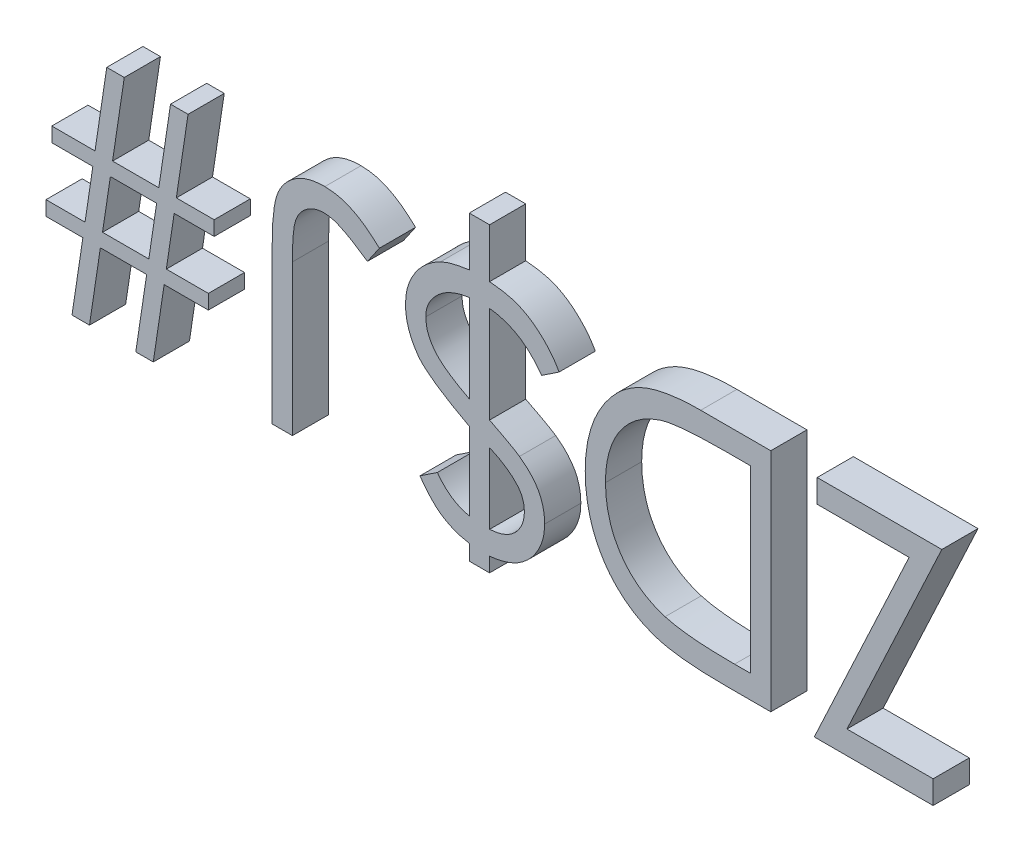
from build123d import *

# Parameters (mm, degrees)
BOSS_EXTRUDE1_DEPTH   = 2.54
BOSS_EXTRUDE1_2_DEPTH = 2.54
BOSS_EXTRUDE1_3_DEPTH = 2.54
BOSS_EXTRUDE1_4_DEPTH = 2.54
BOSS_EXTRUDE1_5_DEPTH = 2.54


with BuildPart() as part:
    # Sketch1 → Boss-Extrude1 (new body)
    with BuildSketch(Plane.XY):
        Polygon((34.338846154, -14.246794872), (34.338846154, -15.875), (25.994294872, -15.875), (32.653399439, -1.628205128), (26.197820513, -1.628205128), (26.197820513, 0), (34.949423077, 0), (28.29031851, -14.246794872), align=None)
    extrude(amount=BOSS_EXTRUDE1_DEPTH)


with BuildPart() as body_2:
    # Sketch1 → Boss-Extrude1 2 (new body)
    with BuildSketch(Plane.XY):
        with BuildLine():
            Line((22.941410256, 0), (22.941410256, -15.875))
            Line((22.941410256, -15.875), (19.73588141, -15.875))
            add(Edge.make_bspline(
                [(19.73588141, -15.875), (19.457075063, -15.872998099), (18.91842265, -15.869130436), (18.140045384, -15.844467286), (17.420874812, -15.801278666), (16.76131934, -15.737155857), (16.160319341, -15.660190517), (15.618837383, -15.56230982), (15.135995956, -15.447195493), (14.83904586, -15.349013294), (14.698621795, -15.302584135)],
                knots=[0, 0, 0, 0, 1.314317071, 2.539253741, 3.67075822, 4.709970291, 5.662644612, 6.526156501, 7.303037452, 8, 8, 8, 8], degree=3))
            add(Edge.make_bspline(
                [(14.698621795, -15.302584135), (14.514932802, -15.23261658), (14.151720273, -15.094268102), (13.634854986, -14.832893895), (13.146633863, -14.537956411), (12.69091192, -14.202693754), (12.266684995, -13.831390189), (11.868615395, -13.427049857), (11.508113044, -12.978878232), (11.172744111, -12.500781919), (10.87920928, -11.988410139), (10.620367969, -11.452025632), (10.399356786, -10.89266914), (10.226908698, -10.306259298), (10.084436776, -9.69842834), (9.988841612, -9.064574245), (9.925341587, -8.408392429), (9.918991318, -7.963095381), (9.915769231, -7.737154447)],
                knots=[0, 0, 0, 0, 0.984696416, 1.947063185, 2.89840987, 3.841051395, 4.778753227, 5.721858861, 6.681155121, 7.65838316, 8.646299769, 9.637283673, 10.641736726, 11.657050558, 12.698485921, 13.768600492, 14.86780186, 16, 16, 16, 16], degree=3))
            add(Edge.make_bspline(
                [(9.915769231, -7.737154447), (9.918623972, -7.540934495), (9.924249538, -7.154262585), (9.974701386, -6.584381856), (10.048173222, -6.031451531), (10.161401466, -5.497899467), (10.300533706, -4.980133415), (10.472258365, -4.480604918), (10.675795689, -3.998974465), (10.911841175, -3.539067515), (11.170301352, -3.10200239), (11.451936145, -2.694704109), (11.747102558, -2.312682032), (12.066565843, -1.964566462), (12.399748897, -1.639516975), (12.757983739, -1.351952797), (13.130053612, -1.08852382), (13.527136575, -0.857229931), (13.952490545, -0.651487142), (14.417226371, -0.477736124), (14.919647899, -0.328210428), (15.463084275, -0.209078587), (16.045723088, -0.113052279), (16.669143739, -0.049103688), (17.332178831, -0.005738563), (17.787471995, -0.001949996), (18.021813902, 0)],
                knots=[0, 0, 0, 0, 1.105894396, 2.179280415, 3.222964075, 4.248423888, 5.251546139, 6.243661943, 7.223682738, 8.196462441, 9.155694589, 10.083899862, 10.986397372, 11.874737962, 12.745335529, 13.607670254, 14.461432187, 15.313100333, 16.195087267, 17.121790994, 18.106827133, 19.14775296, 20.255889161, 21.433815148, 22.679170477, 24, 24, 24, 24], degree=3))
            Line((18.021813902, 0), (22.941410256, 0))
        make_face()
        with BuildLine():
            Line((21.516730769, -1.628205128), (19.694540264, -1.628205128))
            add(Edge.make_bspline(
                [(19.694540264, -1.628205128), (19.432700869, -1.629330422), (18.929087819, -1.631494775), (18.204924759, -1.650486733), (17.543257497, -1.681519806), (16.943992079, -1.724949623), (16.407466862, -1.782410842), (15.932560568, -1.846477365), (15.520829932, -1.926294374), (15.2716857, -1.998643369), (15.156554487, -2.032076322)],
                knots=[0, 0, 0, 0, 1.375205317, 2.645023457, 3.804390687, 4.853969522, 5.800190428, 6.637939096, 7.370582563, 8, 8, 8, 8], degree=3))
            add(Edge.make_bspline(
                [(15.156554487, -2.032076322), (15.011642766, -2.083106363), (14.725280536, -2.183947592), (14.313114425, -2.36796069), (13.928516594, -2.585662374), (13.565075396, -2.829083268), (13.225126547, -3.101982027), (12.910244326, -3.405226531), (12.61794155, -3.735306055), (12.352898266, -4.093332811), (12.113187642, -4.475334316), (11.906078452, -4.880885049), (11.73148775, -5.307709206), (11.588247686, -5.754321793), (11.476569553, -6.220988618), (11.397943753, -6.708880783), (11.349220267, -7.21780561), (11.343404447, -7.564259137), (11.340448718, -7.740334535)],
                knots=[0, 0, 0, 0, 0.998420628, 1.972994, 2.929372424, 3.86770908, 4.81360496, 5.759023883, 6.706048443, 7.676227424, 8.651287839, 9.634325482, 10.632389399, 11.645655052, 12.680158286, 13.74837235, 14.855672678, 16, 16, 16, 16], degree=3))
            add(Edge.make_bspline(
                [(11.340448718, -7.740334535), (11.342779324, -7.925995995), (11.347357821, -8.290729576), (11.404809694, -8.825917417), (11.488945637, -9.340576124), (11.609968629, -9.835076229), (11.766319899, -10.308774375), (11.953406866, -10.764346754), (12.180559812, -11.195930585), (12.437720961, -11.607181217), (12.726431449, -11.99187052), (13.045410565, -12.345491653), (13.391294871, -12.668703328), (13.762490293, -12.962020149), (14.164186769, -13.220225882), (14.589586804, -13.449921673), (15.044682726, -13.645084876), (15.361339128, -13.748849246), (15.522264623, -13.801582532)],
                knots=[0, 0, 0, 0, 1.122272916, 2.204715076, 3.251197285, 4.274229216, 5.279697671, 6.265416158, 7.248880903, 8.225321784, 9.195852973, 10.153576302, 11.101466393, 12.055578741, 13.010401466, 13.985536859, 14.976245305, 16, 16, 16, 16], degree=3))
            add(Edge.make_bspline(
                [(15.522264623, -13.801582532), (15.655393037, -13.83839633), (15.938460572, -13.916672565), (16.400375284, -14.002059076), (16.920236854, -14.077372339), (17.500353356, -14.141135589), (18.140063509, -14.186888797), (18.839859309, -14.221230116), (19.600043229, -14.244392342), (20.127014008, -14.245973979), (20.400519832, -14.246794872)],
                knots=[0, 0, 0, 0, 0.674548936, 1.434276114, 2.292660221, 3.240891867, 4.284742987, 5.42552168, 6.663806718, 8, 8, 8, 8], degree=3))
            Line((20.400519832, -14.246794872), (21.516730769, -14.246794872))
            Line((21.516730769, -14.246794872), (21.516730769, -1.628205128))
        make_face(mode=Mode.SUBTRACT)
    extrude(amount=BOSS_EXTRUDE1_2_DEPTH)


with BuildPart() as body_3:
    # Sketch1 → Boss-Extrude1 3 (new body)
    with BuildSketch(Plane.XY):
        with BuildLine():
            Line((3.199423077, -17.299679487), (1.77474359, -17.299679487))
            Line((1.77474359, -17.299679487), (1.77474359, -16.215269431))
            add(Edge.make_bspline(
                [(1.77474359, -16.215269431), (1.592542457, -16.179897121), (1.238430723, -16.111150293), (0.733066392, -15.945845099), (0.269109359, -15.737068817), (-0.161718203, -15.48116222), (-0.563596033, -15.163924674), (-0.948438666, -14.78317721), (-1.331631903, -14.341404327), (-1.564081734, -14.011585287), (-1.685192308, -13.83974359)],
                knots=[0, 0, 0, 0, 1.027356147, 1.996688285, 2.937535733, 3.840857787, 4.765308625, 5.766057359, 6.836075402, 8, 8, 8, 8], degree=3))
            Line((-1.685192308, -13.83974359), (-0.464038462, -13.025641026))
            add(Edge.make_bspline(
                [(-0.464038462, -13.025641026), (-0.389365788, -13.125546929), (-0.242345453, -13.322248057), (0.003132858, -13.590045804), (0.265400055, -13.825655759), (0.538740275, -14.033859757), (0.826307873, -14.210045089), (1.128329699, -14.353454283), (1.443836134, -14.470855579), (1.663799993, -14.520622247), (1.77474359, -14.545723157)],
                knots=[0, 0, 0, 0, 1.07895845, 2.124322375, 3.137595321, 4.126531539, 5.094133059, 6.050184892, 7.016567989, 8, 8, 8, 8], degree=3))
            Line((1.77474359, -14.545723157), (1.77474359, -9.095052083))
            add(Edge.make_bspline(
                [(1.77474359, -9.095052083), (1.546118831, -8.972318984), (1.108263844, -8.737264391), (0.49222975, -8.380133331), (-0.059576881, -8.045719891), (-0.540213752, -7.723841094), (-0.955302061, -7.422967826), (-1.302643821, -7.141112724), (-1.586250775, -6.879237383), (-1.734672311, -6.69571257), (-1.802855569, -6.611403245)],
                knots=[0, 0, 0, 0, 1.421563521, 2.722533998, 3.90086193, 4.955909988, 5.891017391, 6.708270612, 7.406593414, 8, 8, 8, 8], degree=3))
            add(Edge.make_bspline(
                [(-1.802855569, -6.611403245), (-1.874291682, -6.509558197), (-2.016115683, -6.307362532), (-2.200710502, -5.990152427), (-2.352792444, -5.663319335), (-2.482011875, -5.331595266), (-2.581029824, -4.989949331), (-2.64905919, -4.639649138), (-2.697371466, -4.282795236), (-2.70099778, -4.042054671), (-2.702820513, -3.921048678)],
                knots=[0, 0, 0, 0, 1.034145216, 2.053115814, 3.046762578, 4.028927166, 5.01085441, 5.99964147, 6.994538498, 8, 8, 8, 8], degree=3))
            add(Edge.make_bspline(
                [(-2.702820513, -3.921048678), (-2.695006426, -3.721137582), (-2.679555409, -3.32584764), (-2.552098431, -2.74706121), (-2.338358002, -2.197927792), (-2.048206616, -1.678898432), (-1.687089521, -1.2009681), (-1.2633539, -0.774651282), (-0.782462739, -0.403123714), (-0.425596744, -0.207389487), (-0.24461238, -0.108122997)],
                knots=[0, 0, 0, 0, 1.003260286, 1.983775336, 2.959596404, 3.953447525, 4.960711395, 5.95830558, 6.964555965, 8, 8, 8, 8], degree=3))
            add(Edge.make_bspline(
                [(-0.24461238, -0.108122997), (-0.112048803, -0.050356425), (0.170954882, 0.072966685), (0.644794651, 0.212171138), (1.186574311, 0.324655833), (1.571890331, 0.378633978), (1.77474359, 0.407051282)],
                knots=[0, 0, 0, 0, 0.828676495, 1.769102089, 2.82552272, 4, 4, 4, 4], degree=3))
            Line((1.77474359, 0.407051282), (1.77474359, 3.866987179))
            Line((1.77474359, 3.866987179), (3.199423077, 3.866987179))
            Line((3.199423077, 3.866987179), (3.199423077, 0.407051282))
            add(Edge.make_bspline(
                [(3.199423077, 0.407051282), (3.407498184, 0.387426022), (3.802992044, 0.350123773), (4.361660452, 0.256288418), (4.85450537, 0.130152946), (5.292793113, -0.027971117), (5.693824473, -0.226838292), (6.084657419, -0.458147007), (6.464916471, -0.742029963), (6.841076142, -1.059341256), (7.198065533, -1.412867809), (7.52679408, -1.797335084), (7.82823714, -2.205641591), (7.998670808, -2.498929729), (8.084038462, -2.645833333)],
                knots=[0, 0, 0, 0, 1.246672502, 2.369583394, 3.375855167, 4.278204361, 5.143720243, 6.042872285, 6.983993976, 7.97112367, 8.977335818, 9.977487593, 10.986954044, 12, 12, 12, 12], degree=3))
            Line((8.084038462, -2.645833333), (6.862884615, -3.459935897))
            add(Edge.make_bspline(
                [(6.862884615, -3.459935897), (6.740708101, -3.299568614), (6.501672371, -2.985813463), (6.101002875, -2.565267108), (5.680911857, -2.195397769), (5.232812351, -1.884840846), (4.759256474, -1.631058773), (4.259923549, -1.43806258), (3.738891067, -1.294397731), (3.380401061, -1.245725333), (3.199423077, -1.221153846)],
                knots=[0, 0, 0, 0, 1.091171576, 2.134853779, 3.139926003, 4.117738301, 5.080879018, 6.042512846, 7.011793711, 8, 8, 8, 8], degree=3))
            Line((3.199423077, -1.221153846), (3.199423077, -8.007461939))
            add(Edge.make_bspline(
                [(3.199423077, -8.007461939), (3.332183799, -8.074810385), (3.584619721, -8.202869095), (3.940907673, -8.393267761), (4.262091223, -8.558903845), (4.543006968, -8.713545424), (4.78765388, -8.848850835), (4.993057722, -8.96913257), (5.161057994, -9.071281987), (5.25817693, -9.136117733), (5.301461338, -9.165014022)],
                knots=[0, 0, 0, 0, 1.488099822, 2.829525506, 4.038191342, 5.100394068, 6.034941972, 6.832791195, 7.479793087, 8, 8, 8, 8], degree=3))
            add(Edge.make_bspline(
                [(5.301461338, -9.165014022), (5.443650755, -9.272516804), (5.719294889, -9.48091847), (6.084404062, -9.830252403), (6.392556626, -10.195943645), (6.641753252, -10.583780433), (6.836289548, -10.994599215), (6.967814182, -11.436587467), (7.054714475, -11.907069086), (7.062445055, -12.232329676), (7.066410256, -12.399163662)],
                knots=[0, 0, 0, 0, 1.111703063, 2.15511418, 3.146123089, 4.089346267, 5.024531557, 5.972475508, 6.960033881, 8, 8, 8, 8], degree=3))
            add(Edge.make_bspline(
                [(7.066410256, -12.399163662), (7.061244271, -12.561760946), (7.051001255, -12.884155696), (6.958731677, -13.357969857), (6.8082315, -13.814400968), (6.598102928, -14.246799044), (6.340620976, -14.651842818), (6.037408749, -15.020730427), (5.686535788, -15.345516483), (5.296887915, -15.637205033), (4.851821891, -15.876187299), (4.353339026, -16.067887209), (3.796857954, -16.207883891), (3.403674889, -16.256694838), (3.199423077, -16.282051282)],
                knots=[0, 0, 0, 0, 0.966461706, 1.916281572, 2.859484747, 3.818408359, 4.768270089, 5.708876967, 6.650223357, 7.606219079, 8.596637969, 9.644717611, 10.77647148, 12, 12, 12, 12], degree=3))
            Line((3.199423077, -16.282051282), (3.199423077, -17.299679487))
        make_face()
        with BuildLine():
            add(Edge.make_bspline(
                [(3.199423077, -14.653846154), (3.332245739, -14.640369261), (3.585912227, -14.614630912), (3.945002857, -14.539623448), (4.261288077, -14.430889943), (4.542387592, -14.297314644), (4.784076493, -14.127568962), (5.004688313, -13.940607698), (5.191695634, -13.722202546), (5.351802898, -13.481965211), (5.482371063, -13.223195469), (5.575627741, -12.946027217), (5.630061892, -12.655708577), (5.637818758, -12.457689347), (5.641730769, -12.357822516)],
                knots=[0, 0, 0, 0, 1.288708572, 2.461192779, 3.532677332, 4.512365405, 5.454988357, 6.376533455, 7.298078554, 8.22075996, 9.159205215, 10.08822426, 11.035836136, 12, 12, 12, 12], degree=3))
            add(Edge.make_bspline(
                [(5.641730769, -12.357822516), (5.63701038, -12.231035217), (5.627838608, -11.984686004), (5.533810124, -11.632147935), (5.388812643, -11.306474429), (5.246029682, -11.119400788), (5.174257812, -11.025365585)],
                knots=[0, 0, 0, 0, 1.053300573, 2.046575394, 3.018083574, 4, 4, 4, 4], degree=3))
            add(Edge.make_bspline(
                [(5.174257812, -11.025365585), (5.058997737, -10.900738619), (4.815642206, -10.63760621), (4.356065205, -10.30041367), (3.816621122, -9.968373873), (3.412691701, -9.781850113), (3.199423077, -9.683368389)],
                knots=[0, 0, 0, 0, 0.84476628, 1.783605858, 2.829777417, 4, 4, 4, 4], degree=3))
            Line((3.199423077, -9.683368389), (3.199423077, -14.653846154))
        make_face(mode=Mode.SUBTRACT)
        with BuildLine():
            add(Edge.make_bspline(
                [(1.77474359, -1.26567508), (1.661043264, -1.282120311), (1.438634185, -1.314288808), (1.116657923, -1.388091726), (0.81270773, -1.480494553), (0.52544064, -1.591692906), (0.255831859, -1.722238682), (0.001051744, -1.86860127), (-0.232835584, -2.037612264), (-0.449162122, -2.221215442), (-0.642094372, -2.417700664), (-0.811913241, -2.62153624), (-0.955776282, -2.832295371), (-1.074589832, -3.047944923), (-1.164068523, -3.271673496), (-1.23183715, -3.499031793), (-1.270796298, -3.734207331), (-1.275680477, -3.892290879), (-1.278141026, -3.971930088)],
                knots=[0, 0, 0, 0, 1.238259072, 2.422157181, 3.557390219, 4.661059325, 5.739647889, 6.784463534, 7.824768622, 8.846257151, 9.840331648, 10.79005323, 11.703028131, 12.587810795, 13.438880715, 14.296068018, 15.141594452, 16, 16, 16, 16], degree=3))
            add(Edge.make_bspline(
                [(-1.278141026, -3.971930088), (-1.269765539, -4.127394132), (-1.253115753, -4.436444004), (-1.131365758, -4.89003016), (-0.92485055, -5.320190744), (-0.69457951, -5.663920852), (-0.461824097, -5.930446026), (-0.245035977, -6.133395386), (0.002812289, -6.344601933), (0.289693406, -6.554805004), (0.608844339, -6.773079899), (0.965492102, -6.990698238), (1.356637322, -7.213788882), (1.632202899, -7.357519191), (1.77474359, -7.431865986)],
                knots=[0, 0, 0, 0, 1.147547771, 2.281231607, 3.440470373, 4.658619587, 5.324401976, 6.049794783, 6.849727287, 7.7281402, 8.674892096, 9.704777485, 10.812759543, 12, 12, 12, 12], degree=3))
            Line((1.77474359, -7.431865986), (1.77474359, -1.26567508))
        make_face(mode=Mode.SUBTRACT)
    extrude(amount=BOSS_EXTRUDE1_3_DEPTH)


with BuildPart() as body_4:
    # Sketch1 → Boss-Extrude1 4 (new body)
    with BuildSketch(Plane.XY):
        with BuildLine():
            Line((-10.640320513, -15.875), (-12.065, -15.875))
            Line((-12.065, -15.875), (-12.065, -5.154922877))
            add(Edge.make_bspline(
                [(-12.065, -5.154922877), (-12.063582616, -4.956687713), (-12.060861067, -4.576052009), (-12.045742756, -4.027815665), (-12.018148671, -3.526107806), (-11.976666257, -3.072275053), (-11.927245363, -2.665616212), (-11.864500419, -2.305534543), (-11.789875419, -1.991879377), (-11.676881582, -1.639860776), (-11.492687889, -1.252425451), (-11.209955548, -0.837752263), (-10.866161488, -0.4710466), (-10.462180428, -0.159034759), (-10.006689759, 0.098526524), (-9.497804289, 0.278511701), (-8.94483971, 0.389447011), (-8.56108773, 0.401065432), (-8.363377404, 0.407051282)],
                knots=[0, 0, 0, 0, 1.23761369, 2.376369303, 3.423688776, 4.373947637, 5.221061685, 5.980504468, 6.65465141, 7.232267317, 8.286152468, 9.319580031, 10.354278202, 11.410653829, 12.495036873, 13.606623453, 14.766924254, 16, 16, 16, 16], degree=3))
            add(Edge.make_bspline(
                [(-8.363377404, 0.407051282), (-8.208290429, 0.402221006), (-7.898363308, 0.392568142), (-7.435763201, 0.311882154), (-6.977355624, 0.185132201), (-6.5163137, 0.002937725), (-6.046853924, -0.243768142), (-5.556921378, -0.562503578), (-5.047330661, -0.961721335), (-4.710740902, -1.265608307), (-4.534551282, -1.424679487)],
                knots=[0, 0, 0, 0, 0.854547984, 1.707735923, 2.581180402, 3.47327429, 4.435225703, 5.500268456, 6.691502816, 8, 8, 8, 8], degree=3))
            Line((-4.534551282, -1.424679487), (-5.374094551, -2.645833333))
            add(Edge.make_bspline(
                [(-5.374094551, -2.645833333), (-5.568187077, -2.512940434), (-5.934374744, -2.26221599), (-6.46687409, -1.929373267), (-6.947592967, -1.658971646), (-7.258987317, -1.516162085), (-7.402990785, -1.450120192)],
                knots=[0, 0, 0, 0, 1.196638425, 2.257656398, 3.194257951, 4, 4, 4, 4], degree=3))
            add(Edge.make_bspline(
                [(-7.402990785, -1.450120192), (-7.490241944, -1.414023727), (-7.660766832, -1.34347629), (-7.925274369, -1.27603139), (-8.184534462, -1.227193992), (-8.357856661, -1.223141695), (-8.442879607, -1.221153846)],
                knots=[0, 0, 0, 0, 1.055403208, 2.062694816, 3.049657822, 4, 4, 4, 4], degree=3))
            add(Edge.make_bspline(
                [(-8.442879607, -1.221153846), (-8.5525712, -1.22572942), (-8.768360041, -1.234730636), (-9.083743403, -1.316376327), (-9.384397662, -1.442544103), (-9.663114546, -1.623315865), (-9.916894796, -1.838744087), (-10.130139318, -2.095787811), (-10.303375803, -2.384946573), (-10.413831014, -2.656326302), (-10.480291486, -2.90594176), (-10.52434087, -3.134314952), (-10.556210973, -3.402372255), (-10.590552324, -3.708413233), (-10.609050275, -4.054542011), (-10.630625773, -4.439164259), (-10.638305937, -4.863387768), (-10.639628497, -5.159164892), (-10.640320513, -5.313927284)],
                knots=[0, 0, 0, 0, 0.997338315, 1.961996122, 2.948199042, 3.955162468, 4.975046525, 5.968827587, 6.982064989, 8.034375777, 8.624523585, 9.332616724, 10.150461195, 11.082242492, 12.136676661, 13.306224245, 14.590509051, 16, 16, 16, 16], degree=3))
            Line((-10.640320513, -5.313927284), (-10.640320513, -15.875))
        make_face()
    extrude(amount=BOSS_EXTRUDE1_4_DEPTH)


with BuildPart() as body_5:
    # Sketch1 → Boss-Extrude1 5 (new body)
    with BuildSketch(Plane.XY):
        Polygon((-27.532948718, -6.512820513), (-27.532948718, -5.495192308), (-24.499144631, -5.495192308), (-23.675501803, 0), (-22.444807692, 0), (-23.268450521, -5.495192308), (-20.021580529, -5.495192308), (-19.1979377, 0), (-17.96724359, 0), (-18.790886418, -5.495192308), (-16.135512821, -5.495192308), (-16.135512821, -6.512820513), (-18.943530649, -6.512820513), (-19.493685897, -10.176282051), (-16.542564103, -10.176282051), (-16.542564103, -11.193910256), (-19.646330128, -11.193910256), (-20.409551282, -16.282051282), (-21.637065304, -16.282051282), (-20.873844151, -11.193910256), (-24.123894231, -11.193910256), (-24.887115385, -16.282051282), (-26.114629407, -16.282051282), (-25.351408253, -11.193910256), (-27.94, -11.193910256), (-27.94, -10.176282051), (-25.198764022, -10.176282051), (-24.651788862, -6.512820513), align=None)
        Polygon((-23.97125, -10.176282051), (-20.72119992, -10.176282051), (-20.17422476, -6.512820513), (-23.421094752, -6.512820513), align=None, mode=Mode.SUBTRACT)
    extrude(amount=BOSS_EXTRUDE1_5_DEPTH)


solid = Compound([part.part, body_2.part, body_3.part, body_4.part, body_5.part])
